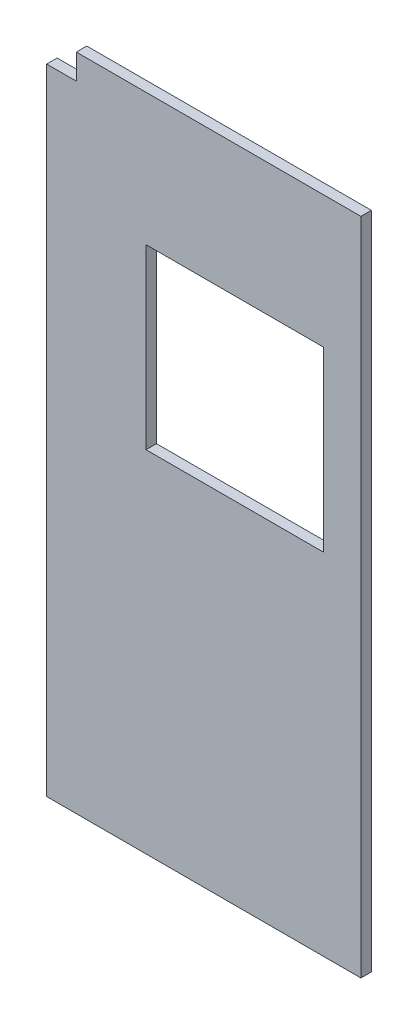
from build123d import *

# Parameters (mm, degrees)
SKETCH1_W           = 1146.302
SKETCH1_H           = 2405.888
SKETCH1_W_2         = 647.7
SKETCH1_H_2         = 647.7
BOSS_EXTRUDE1_DEPTH = 38.1
SKETCH2_W           = 108.204
SKETCH2_H           = 91.948
CUT_EXTRUDE1_DEPTH  = 38.1


with BuildPart() as part:
    # Sketch1 → Boss-Extrude1 (new body)
    with BuildSketch(Plane.XY):
        Rectangle(SKETCH1_W, SKETCH1_H)
        with Locations((113.157, 397.764)):
            Rectangle(SKETCH1_W_2, SKETCH1_H_2, mode=Mode.SUBTRACT)
    extrude(amount=BOSS_EXTRUDE1_DEPTH)

    # Sketch2 → Cut-Extrude1 (cut)
    with BuildSketch(Plane.XY.offset(38.1)):
        with Locations((-519.049, 1156.97)):
            Rectangle(SKETCH2_W, SKETCH2_H)
    extrude(amount=-CUT_EXTRUDE1_DEPTH, mode=Mode.SUBTRACT)


solid = part.part
